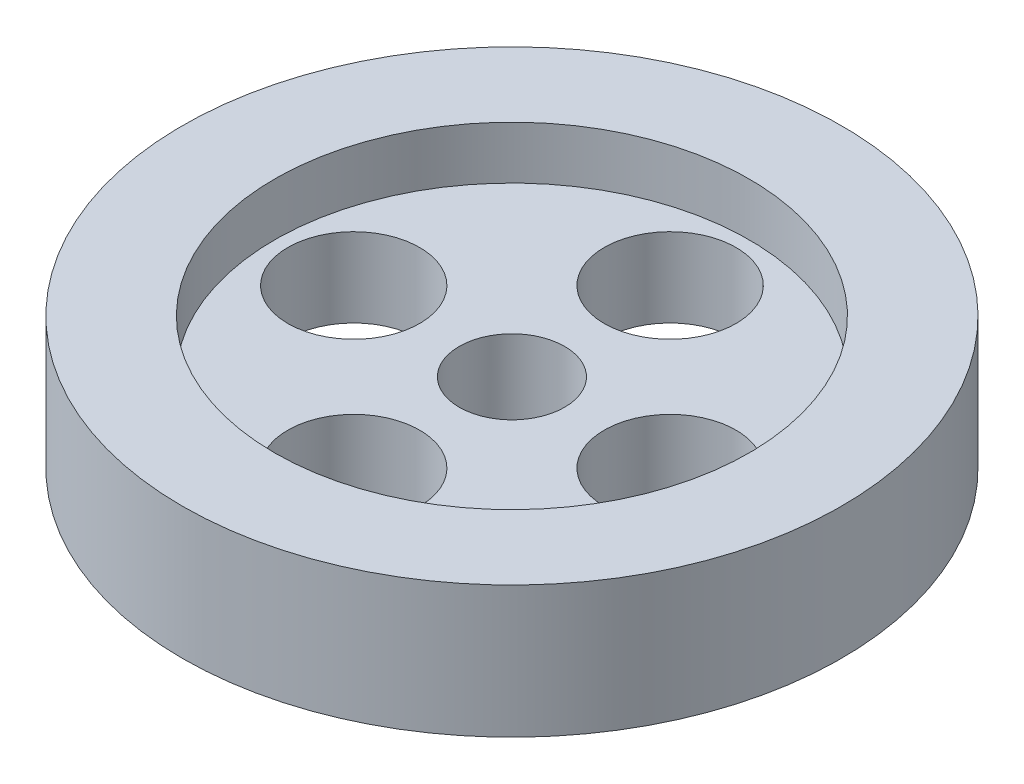
from build123d import *

# Parameters (mm, degrees)
SKETCH1_R           = 25
SKETCH1_R_2         = 4
SKETCH1_R_3         = 5
BOSS_EXTRUDE1_DEPTH = 10
SKETCH2_R           = 18
CUT_EXTRUDE1_DEPTH  = 4
SKETCH3_R           = 6
BOSS_EXTRUDE2_DEPTH = 1
SKETCH4_R           = 4
CUT_EXTRUDE2_DEPTH  = 13


with BuildPart() as part:
    # Sketch1 → Boss-Extrude1 (new body)
    with BuildSketch(Plane(origin=(0, 0, 0), x_dir=(1, 0, 0), z_dir=(0, 1, 0))):
        Circle(SKETCH1_R)
        Circle(SKETCH1_R_2, mode=Mode.SUBTRACT)
        with Locations((0, 12)):
            Circle(SKETCH1_R_3, mode=Mode.SUBTRACT)
        with Locations((12, 0)):
            Circle(SKETCH1_R_3, mode=Mode.SUBTRACT)
        with Locations((0, -12)):
            Circle(SKETCH1_R_3, mode=Mode.SUBTRACT)
        with Locations((-12, 0)):
            Circle(SKETCH1_R_3, mode=Mode.SUBTRACT)
    extrude(amount=BOSS_EXTRUDE1_DEPTH)

    # Sketch2 → Cut-Extrude1 (cut)
    with BuildSketch(Plane(origin=(0, 10, 0), x_dir=(1, 0, 0), z_dir=(0, 1, 0))):
        Circle(SKETCH2_R)
    extrude(amount=-CUT_EXTRUDE1_DEPTH, mode=Mode.SUBTRACT)

    # Sketch3 → Boss-Extrude2 (add)
    with BuildSketch(Plane.XZ):
        Circle(SKETCH3_R)
    extrude(amount=BOSS_EXTRUDE2_DEPTH)

    # Sketch4 → Cut-Extrude2 (cut)
    with BuildSketch(Plane(origin=(0, 0, 0), x_dir=(1, 0, 0), z_dir=(0, 1, 0))):
        Circle(SKETCH4_R)
    extrude(amount=-CUT_EXTRUDE2_DEPTH, mode=Mode.SUBTRACT)


solid = part.part
